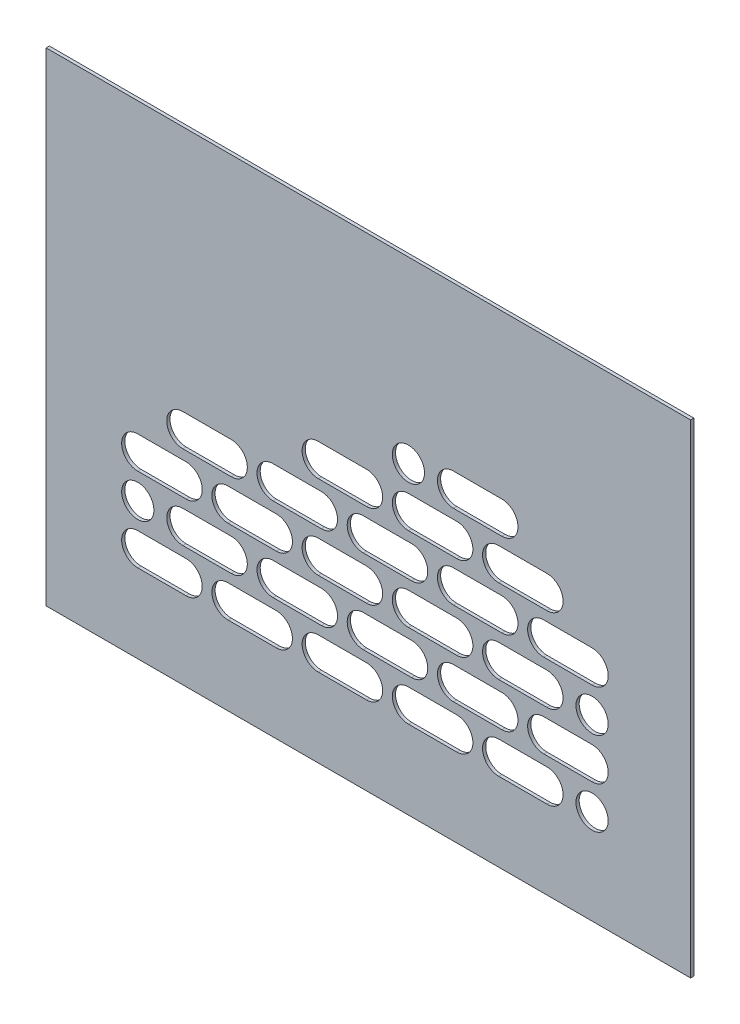
from build123d import *

# Parameters (mm, degrees)
SKIZZE1_W                       = 200
SKIZZE1_H                       = 150
AUFSATZ_LINEAR_AUSTRAGEN1_DEPTH = 1
SCHNITT_LINEAR_AUSTRAGEN5_DEPTH = 2
LINEARES_MUSTER2_COUNT          = 5
LINEARES_MUSTER2_PITCH          = 28
LINEARES_MUSTER2_COUNT_DIR2     = 3
LINEARES_MUSTER2_PITCH_DIR2     = 26
SCHNITT_LINEAR_AUSTRAGEN6_DEPTH = 2
LINEARES_MUSTER3_COUNT          = 5
LINEARES_MUSTER3_PITCH          = 28
LINEARES_MUSTER3_COUNT_DIR2     = 3
LINEARES_MUSTER3_PITCH_DIR2     = 26
SKIZZE9_R                       = 5
SCHNITT_LINEAR_AUSTRAGEN7_DEPTH = 2


with BuildPart() as part:
    # Skizze1 → Aufsatz-Linear austragen1 (new body)
    with BuildSketch(Plane.XY):
        with Locations((100, 75)):
            Rectangle(SKIZZE1_W, SKIZZE1_H)
    extrude(amount=AUFSATZ_LINEAR_AUSTRAGEN1_DEPTH)

    # Langlochmuster → Schnitt-Linear austragen5 (cut, through all)
    with BuildSketch(Plane.XY.offset(1)):
        with BuildLine():
            Line((28.425192668, 34.450971961), (43.425192668, 34.450971961))
            ThreePointArc((43.425192668, 34.450971961), (48.425192668, 29.450971961), (43.425192668, 24.450971961))
            Line((43.425192668, 24.450971961), (28.425192668, 24.450971961))
            ThreePointArc((28.425192668, 24.450971961), (23.425192668, 29.450971961), (28.425192668, 34.450971961))
        make_face()
    schnitt_linear_austragen5 = extrude(amount=-SCHNITT_LINEAR_AUSTRAGEN5_DEPTH, mode=Mode.SUBTRACT)

    # Lineares Muster2: Schnitt-Linear austragen5 5 × 3, 2 skipped
    with Locations(*[(i * LINEARES_MUSTER2_PITCH, j * LINEARES_MUSTER2_PITCH_DIR2, 0) for i in range(LINEARES_MUSTER2_COUNT) for j in range(LINEARES_MUSTER2_COUNT_DIR2) if (i, j) not in ((0, 0), (0, 2), (1, 2))]):
        add(schnitt_linear_austragen5, mode=Mode.SUBTRACT)

    # Skizze8_3 → Schnitt-Linear austragen6 (cut, through all)
    with BuildSketch(Plane.XY.offset(1)):
        with BuildLine():
            Line((42.425192668, 47.450971961), (57.425192668, 47.450971961))
            ThreePointArc((57.425192668, 47.450971961), (62.425192668, 42.450971961), (57.425192668, 37.450971961))
            Line((57.425192668, 37.450971961), (42.425192668, 37.450971961))
            ThreePointArc((42.425192668, 37.450971961), (37.425192668, 42.450971961), (42.425192668, 47.450971961))
        make_face()
    schnitt_linear_austragen6 = extrude(amount=-SCHNITT_LINEAR_AUSTRAGEN6_DEPTH, mode=Mode.SUBTRACT)

    # Lineares Muster3: Schnitt-Linear austragen6 5 × 3, 4 skipped
    with Locations(*[(i * LINEARES_MUSTER3_PITCH, j * LINEARES_MUSTER3_PITCH_DIR2, 0) for i in range(LINEARES_MUSTER3_COUNT) for j in range(LINEARES_MUSTER3_COUNT_DIR2) if (i, j) not in ((0, 0), (0, 2), (1, 2), (2, 2), (4, 2))]):
        add(schnitt_linear_austragen6, mode=Mode.SUBTRACT)

    # Skizze9 → Schnitt-Linear austragen7 (cut, through all)
    with BuildSketch(Plane.XY.offset(1)):
        with Locations((28.425192668, 42.450971961)):
            Circle(SKIZZE9_R)
        with Locations((112.425192668, 94.450971961)):
            Circle(SKIZZE9_R)
        with Locations((169.425192668, 55.450971961)):
            Circle(SKIZZE9_R)
        with Locations((169.425192668, 29.450971961)):
            Circle(SKIZZE9_R)
    extrude(amount=-SCHNITT_LINEAR_AUSTRAGEN7_DEPTH, mode=Mode.SUBTRACT)


solid = part.part
